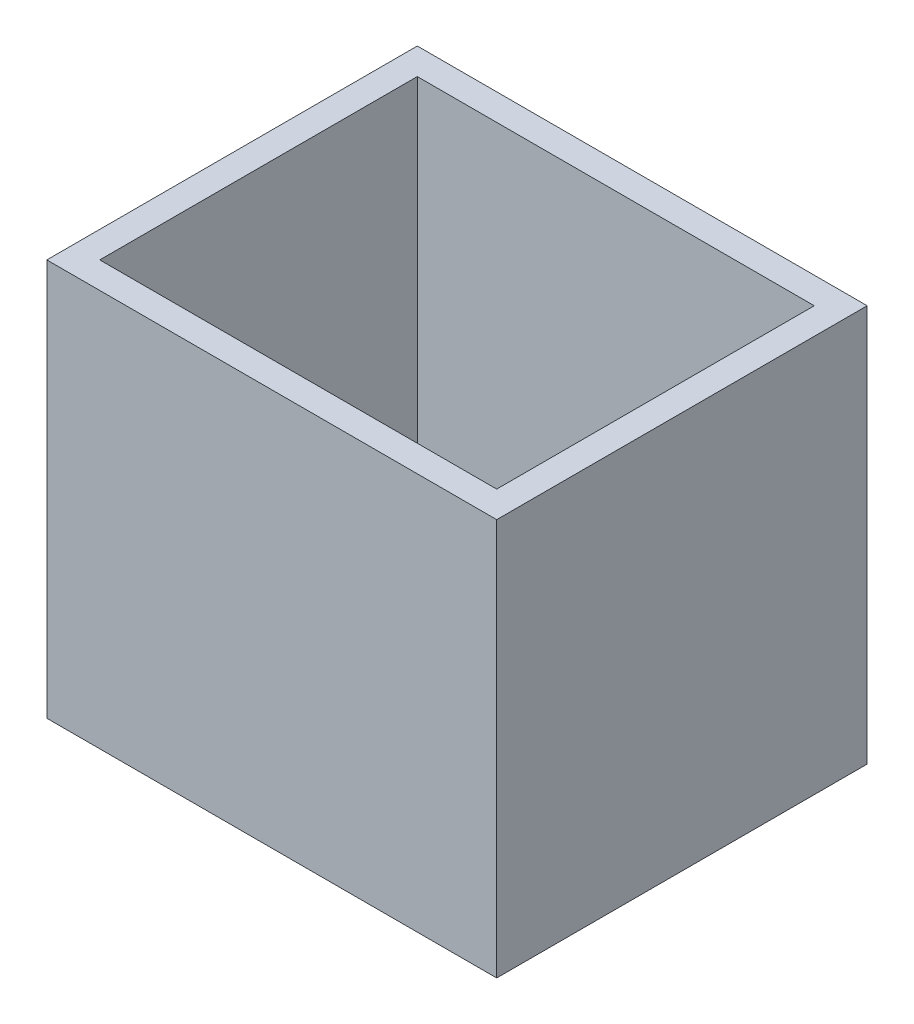
from build123d import *

# Parameters (mm, degrees)
SKETCH1_W           = 85
SKETCH1_H           = 70
BOSS_EXTRUDE1_DEPTH = 75
SKETCH2_W           = 75
SKETCH2_H           = 60
CUT_EXTRUDE1_DEPTH  = 70
SKETCH3_W           = 20
SKETCH3_H           = 20
BOSS_EXTRUDE2_DEPTH = 25


with BuildPart() as part:
    # Sketch1 → Boss-Extrude1 (new body)
    with BuildSketch(Plane(origin=(0, 0, 0), x_dir=(1, 0, 0), z_dir=(0, 1, 0))):
        with Locations((42.5, 35)):
            Rectangle(SKETCH1_W, SKETCH1_H)
    extrude(amount=BOSS_EXTRUDE1_DEPTH)

    # Sketch2 → Cut-Extrude1 (cut)
    with BuildSketch(Plane(origin=(0, 75, 0), x_dir=(1, 0, 0), z_dir=(0, 1, 0))):
        with Locations((42.5, 35)):
            Rectangle(SKETCH2_W, SKETCH2_H)
    extrude(amount=-CUT_EXTRUDE1_DEPTH, mode=Mode.SUBTRACT)

    # Sketch3 → Boss-Extrude2 (add)
    with BuildSketch(Plane(origin=(0, 5, 0), x_dir=(1, 0, 0), z_dir=(0, 1, 0))):
        with Locations((65, 32.492591032)):
            Rectangle(SKETCH3_W, SKETCH3_H)
    extrude(amount=BOSS_EXTRUDE2_DEPTH)


solid = part.part
